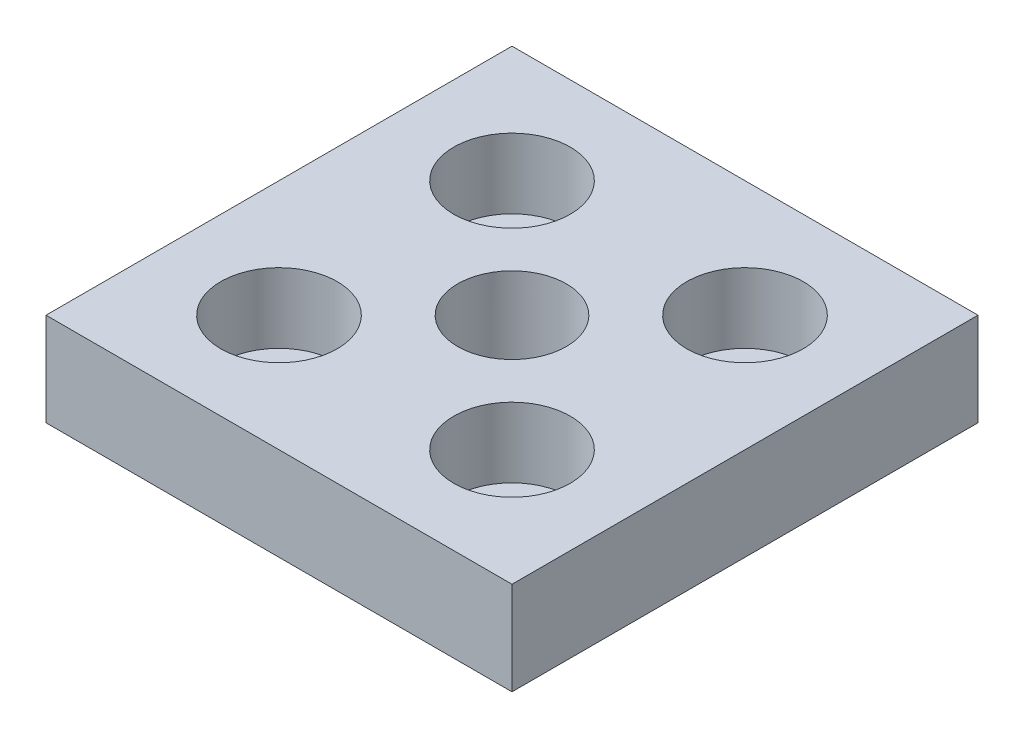
from build123d import *

# Parameters (mm, degrees)
SKETCH_1_W             = 60
SKETCH_1_H             = 60
EXTRUDE_1_DEPTH        = 12
HOLE_WIZARD_M161_D     = 14
HOLE_WIZARD_M161_DEPTH = 12
SKETCH_12_R            = 4.5
CUT_EXTRUDE_1_DEPTH    = 13
SKETCH_13_R            = 7.5
CUT_EXTRUDE_2_DEPTH    = 9


with BuildPart() as part:
    # Эскиз1 → Бобышка-Вытянуть1 (new body)
    with BuildSketch(Plane(origin=(0, 0, 0), x_dir=(1, 0, 0), z_dir=(0, 1, 0))):
        Rectangle(SKETCH_1_W, SKETCH_1_H)
    extrude(amount=EXTRUDE_1_DEPTH)

    # Отверстие обработанное метчиком M161
    with Locations(Plane(origin=(0, 12, 0), x_dir=(1, 0, 0), z_dir=(0, 1, 0))):
        with Locations((0, 0)):
            Hole(HOLE_WIZARD_M161_D / 2, depth=HOLE_WIZARD_M161_DEPTH)

    # Эскиз12 → Вырез-Вытянуть1 (cut, through all)
    with BuildSketch(Plane(origin=(0, 12, 0), x_dir=(1, 0, 0), z_dir=(0, 1, 0))):
        with Locations(Location((-15, 15, 0), (0, 0, 270))):  # turned: the seam where the file's is
            Circle(SKETCH_12_R)
        with Locations(Location((15, 15, 0), (0, 0, 270))):  # turned: the seam where the file's is
            Circle(SKETCH_12_R)
        with Locations(Location((15, -15, 0), (0, 0, 270))):  # turned: the seam where the file's is
            Circle(SKETCH_12_R)
        with Locations(Location((-15, -15, 0), (0, 0, 270))):  # turned: the seam where the file's is
            Circle(SKETCH_12_R)
    extrude(amount=-CUT_EXTRUDE_1_DEPTH, mode=Mode.SUBTRACT)

    # Эскиз13 → Вырез-Вытянуть2 (cut)
    with BuildSketch(Plane(origin=(0, 12, 0), x_dir=(1, 0, 0), z_dir=(0, 1, 0))):
        with Locations(Location((-15, 15, 0), (0, 0, 270))):  # turned: the seam where the file's is
            Circle(SKETCH_13_R)
        with Locations(Location((15, 15, 0), (0, 0, 270))):  # turned: the seam where the file's is
            Circle(SKETCH_13_R)
        with Locations(Location((15, -15, 0), (0, 0, 270))):  # turned: the seam where the file's is
            Circle(SKETCH_13_R)
        with Locations(Location((-15, -15, 0), (0, 0, 270))):  # turned: the seam where the file's is
            Circle(SKETCH_13_R)
    extrude(amount=-CUT_EXTRUDE_2_DEPTH, mode=Mode.SUBTRACT)


solid = part.part
